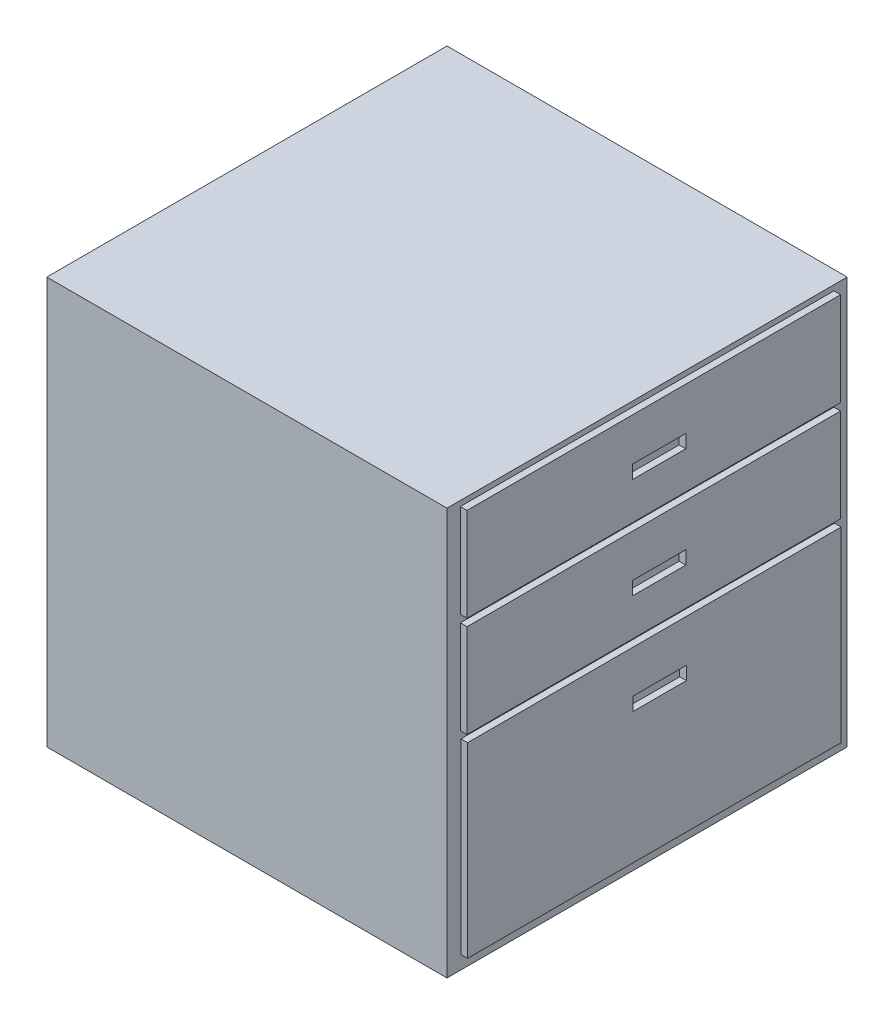
from build123d import *

# Parameters (mm, degrees)
SKETCH1_W           = 600
SKETCH1_H           = 610
BOSS_EXTRUDE1_DEPTH = 600
SKETCH2_W           = 560
SKETCH2_H           = 140
SKETCH2_W_2         = 80
SKETCH2_H_2         = 20
SKETCH2_H_3         = 280
BOSS_EXTRUDE2_DEPTH = 10


with BuildPart() as part:
    # Sketch1 → Boss-Extrude1 (new body)
    with BuildSketch(Plane.XY):
        with Locations((-300, -305)):
            Rectangle(SKETCH1_W, SKETCH1_H)
    extrude(amount=BOSS_EXTRUDE1_DEPTH)

    # Sketch2 → Boss-Extrude2 (add)
    with BuildSketch(Plane(origin=(0, 0, 0), x_dir=(0, 0, -1), z_dir=(1, 0, 0))):
        with Locations((-300, -77.913832036)):
            Rectangle(SKETCH2_W, SKETCH2_H)
        with Locations((-292, -81.913832036)):
            Rectangle(SKETCH2_W_2, SKETCH2_H_2, mode=Mode.SUBTRACT)
        with Locations((-300, -228.913832036)):
            Rectangle(SKETCH2_W, SKETCH2_H)
        with Locations((-292, -232.913832036)):
            Rectangle(SKETCH2_W_2, SKETCH2_H_2, mode=Mode.SUBTRACT)
        with Locations((-299.167600113, -449.913832036)):
            Rectangle(SKETCH2_W, SKETCH2_H_3)
        with Locations((-291.167600113, -383.400082601)):
            Rectangle(SKETCH2_W_2, SKETCH2_H_2, mode=Mode.SUBTRACT)
    extrude(amount=BOSS_EXTRUDE2_DEPTH)


solid = part.part
